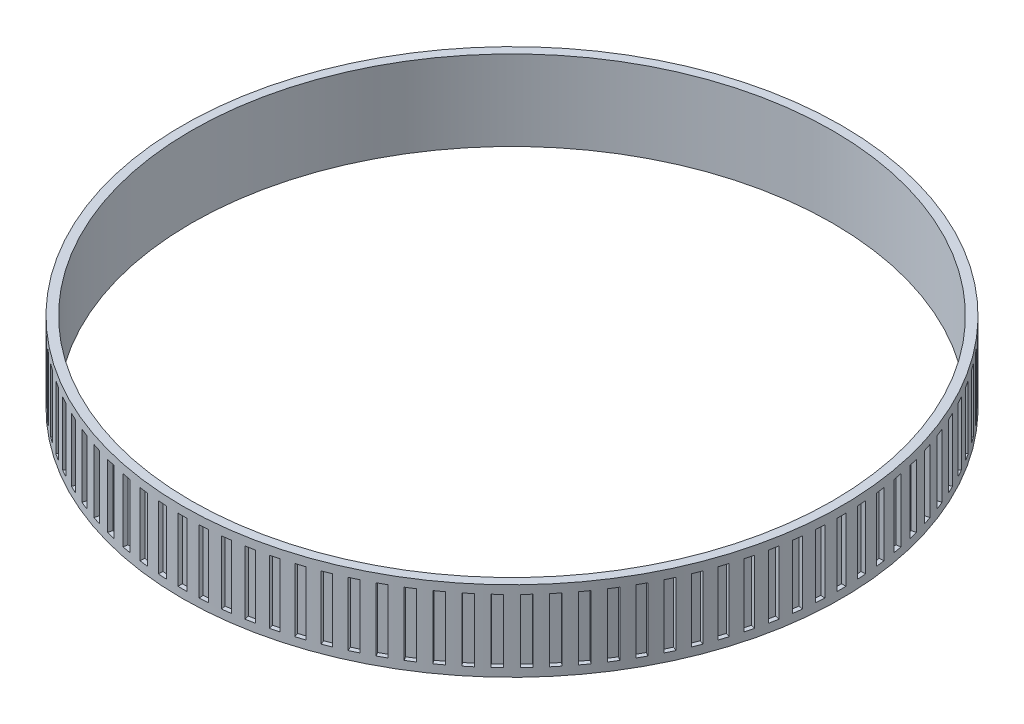
from build123d import *

# Parameters (mm, degrees)
SKETCH1_W          = 1
SKETCH1_H          = 9
SKETCH3_W          = 1
SKETCH3_H          = 7.119786146
CUT_EXTRUDE1_DEPTH = 0.5
CIRPATTERN1_COUNT  = 100


with BuildPart() as part:
    # Sketch1 → Revolve1 (revolve)
    with BuildSketch(Plane.XY):
        with Locations((0.5, 4.5)):
            Rectangle(SKETCH1_W, SKETCH1_H)
    revolve(axis=Axis((37, 9.787121824, 0), (0, -1, 0)))

    # Sketch3 → Cut-Extrude1 (cut, symmetric)
    with BuildSketch(Plane.XY):
        with Locations((0, 4.5)):
            Rectangle(SKETCH3_W, SKETCH3_H)
    cut_extrude1 = extrude(amount=CUT_EXTRUDE1_DEPTH, both=True, mode=Mode.SUBTRACT)

    # CirPattern1: Cut-Extrude1 ×100 about axis
    cirpattern1_axis = Axis((37, 0, 0), (0, 1, 0))
    for i in range(1, CIRPATTERN1_COUNT):
        add(cut_extrude1.rotate(cirpattern1_axis, i * 360 / CIRPATTERN1_COUNT), mode=Mode.SUBTRACT)


solid = part.part
